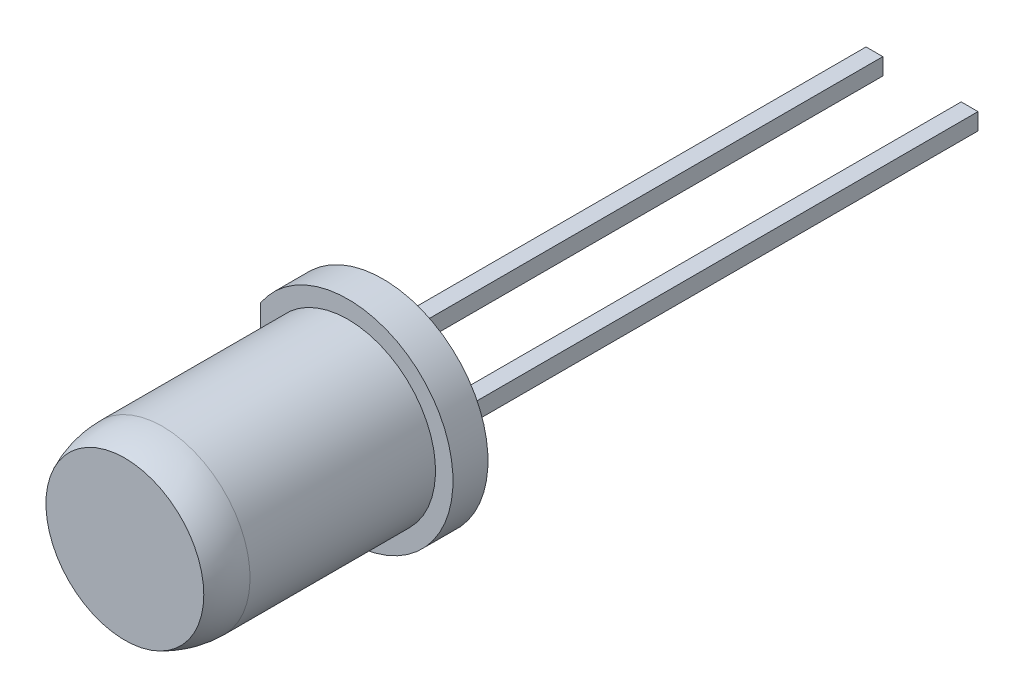
from build123d import *

# Parameters (mm, degrees)
ESBO_O1_R                  = 3
RESSALTO_EXTRUS_O1_DEPTH   = 1
CORTE_EXTRUS_O1_DEPTH      = 1
ESBO_O5_W                  = 0.48
ESBO_O5_H                  = 0.48
RESSALTO_EXTRUS_O2_DEPTH   = 25
RESSALTO_EXTRUS_O2_2_DEPTH = 25
ESBO_O6_W                  = 0.48
ESBO_O6_H                  = 0.48
RESSALTO_EXTRUS_O3_DEPTH   = 2
CORTE_EXTRUS_O2_DEPTH      = 0.24
RESSALTO_EXTRUS_O4_DEPTH   = 0.24
RESSALTO_EXTRUS_O4_2_DEPTH = 0.24
ESBO_O12_R                 = 0.2
CORTE_EXTRUS_O3_DEPTH      = 0.1
SKETCH1_W                  = 40.503516259
SKETCH1_H                  = 63.372853313
SKETCH1_W_2                = 20.905522142
SKETCH1_H_2                = 22.782231705
CUT_EXTRUDE1_DEPTH         = 4
CUT_EXTRUDE1_DEPTH_BACK    = 4


with BuildPart() as part:
    # Esboço1 → Ressalto-extrusão1 (new body)
    with BuildSketch(Plane.XY):
        Circle(ESBO_O1_R)
    extrude(amount=RESSALTO_EXTRUS_O1_DEPTH)

    # Esboço3 → Revolução1 (revolve)
    with BuildSketch(Plane(origin=(0, 0, 0), x_dir=(0, 0, -1), z_dir=(1, 0, 0))):
        with BuildLine():
            Line((-1, 0), (-8.8, 0))
            ThreePointArc((-8.8, 0), (-8.067766953, 1.767766953), (-6.3, 2.5))
            Line((-6.3, 2.5), (-1, 2.5))
            Line((-1, 2.5), (-1, 0))
        make_face()
    revolve(axis=Axis((0, 0, 1), (0, 0, 1)))

    # Esboço4 → Corte-extrusão1 (cut)
    with BuildSketch(Plane(origin=(0, 0, 0), x_dir=(-1, 0, 0), z_dir=(0, 0, -1))):
        with BuildLine():
            Line((2.5, 1.658312395), (2.5, -1.658312395))
            ThreePointArc((2.5, -1.658312395), (3, 0), (2.5, 1.658312395))
        make_face()
    extrude(amount=-CORTE_EXTRUS_O1_DEPTH, mode=Mode.SUBTRACT)

    # Esboço7 → Corte-extrusão2 (cut, symmetric)
    with BuildSketch(Plane(origin=(0, 0, 0), x_dir=(1, 0, 0), z_dir=(0, 1, 0))):
        Polygon((-1.6, 0), (-1.6, -3.5), (-1.3, -4), (1.2, -4), (0.02, -2), (-1.12, -2), (-1.12, 0), align=None)
        Polygon((1.6, 0), (1.6, -4), (1.4, -4), (0.22, -2), (1.12, -2), (1.12, 0), align=None)
    extrude(amount=CORTE_EXTRUS_O2_DEPTH, both=True, mode=Mode.SUBTRACT)


with BuildPart() as body_2:
    # Esboço5 → Ressalto-extrusão2 (new body)
    with BuildSketch(Plane(origin=(0, 0, 0), x_dir=(-1, 0, 0), z_dir=(0, 0, -1))):
        with Locations((-1.36, 0)):
            Rectangle(ESBO_O5_W, ESBO_O5_H)
    extrude(amount=RESSALTO_EXTRUS_O2_DEPTH)


with BuildPart() as body_3:
    # Esboço5 → Ressalto-extrus_o2 2 (new body)
    with BuildSketch(Plane(origin=(0, 0, 0), x_dir=(-1, 0, 0), z_dir=(0, 0, -1))):
        with Locations((1.36, 0)):
            Rectangle(ESBO_O5_W, ESBO_O5_H)
    extrude(amount=RESSALTO_EXTRUS_O2_2_DEPTH)


with BuildPart() as body_4:
    # Esboço6 → Ressalto-extrusão3 (new body)
    with BuildSketch(Plane(origin=(0, 0, -25), x_dir=(-1, 0, 0), z_dir=(0, 0, -1))):
        with Locations((-1.36, 0)):
            Rectangle(ESBO_O6_W, ESBO_O6_H)
    extrude(amount=RESSALTO_EXTRUS_O3_DEPTH)


with BuildPart() as body_5:
    # Esboço8 → Ressalto-extrusão4 (new body, symmetric)
    with BuildSketch(Plane(origin=(0, 0, 0), x_dir=(1, 0, 0), z_dir=(0, 1, 0))):
        Polygon((-1.3, -4), (1.2, -4), (0.02, -2), (-1.12, -2), (-1.12, 0), (-1.6, 0), (-1.6, -3.5), align=None)
    extrude(amount=RESSALTO_EXTRUS_O4_DEPTH, both=True)

    # Combinar2: union body 3
    add(body_3.part)

    # Esboço10 → Corte-Revolução1 (revolve, cut)
    with BuildSketch(Plane(origin=(0, 0, 0), x_dir=(1, 0, 0), z_dir=(0, 1, 0))):
        with BuildLine():
            Line((-0.05, -4), (-0.05, -3.7))
            ThreePointArc((-0.05, -3.7), (-0.341547595, -3.780754009), (-0.55, -4))
            Line((-0.55, -4), (-0.05, -4))
        make_face()
    revolve(axis=Axis((-0.05, 0, 4), (0, 0, -1)), mode=Mode.SUBTRACT)


with BuildPart() as body_6:
    # Esboço8 → Ressalto-extrus_o4 2 (new body, symmetric)
    with BuildSketch(Plane(origin=(0, 0, 0), x_dir=(1, 0, 0), z_dir=(0, 1, 0))):
        Polygon((0.22, -2), (1.4, -4), (1.6, -4), (1.6, 0), (1.12, 0), (1.12, -2), align=None)
    extrude(amount=RESSALTO_EXTRUS_O4_2_DEPTH, both=True)

    # Combinar1: union body 4, body 2
    add(body_4.part)
    add(body_2.part)


with BuildPart() as body_4_2:
    # Esboço11 → Revolução2 (revolve)
    with BuildSketch(Plane(origin=(0, 0, 0), x_dir=(1, 0, 0), z_dir=(0, 1, 0))):
        with BuildLine():
            Line((-0.55, -4), (-0.05, -4))
            Line((-0.05, -4), (-0.05, -3.7))
            ThreePointArc((-0.05, -3.7), (-0.341547595, -3.780754009), (-0.55, -4))
        make_face()
    revolve(axis=Axis((-0.05, 0, 4), (0, 0, -1)))

    # Combinar3: union body 5
    add(body_5.part)

    # Esboço12 → Corte-extrusão3 (cut)
    with BuildSketch(Plane.XY.offset(4)):
        with Locations((-0.05, 0)):
            Circle(ESBO_O12_R)
    extrude(amount=-CORTE_EXTRUS_O3_DEPTH, mode=Mode.SUBTRACT)


with BuildPart() as cut_extrude1_tool:
    # Sketch1 → Cut-Extrude1 (new body, two sides)
    with BuildSketch(Plane(origin=(0, 0, 0), x_dir=(1, 0, 0), z_dir=(0, 1, 0))) as cut_extrude1_sk:
        with Locations((0.838090288, 1.622898698)):
            Rectangle(SKETCH1_W, SKETCH1_H)
        with Locations((-0.529063495, 4.013216122)):
            Rectangle(SKETCH1_W_2, SKETCH1_H_2, mode=Mode.SUBTRACT)
    extrude(amount=CUT_EXTRUDE1_DEPTH)
    extrude(cut_extrude1_sk.sketch, amount=-CUT_EXTRUDE1_DEPTH_BACK)


with BuildPart() as part_1:
    add(part.part)

    # Cut-Extrude1: cut by cut_extrude1_tool
    add(cut_extrude1_tool.part, mode=Mode.SUBTRACT)


with BuildPart() as body_6_1:
    add(body_6.part)

    # Cut-Extrude1: cut by cut_extrude1_tool
    add(cut_extrude1_tool.part, mode=Mode.SUBTRACT)


with BuildPart() as body_4_2_1:
    add(body_4_2.part)

    # Cut-Extrude1: cut by cut_extrude1_tool
    add(cut_extrude1_tool.part, mode=Mode.SUBTRACT)


solid = Compound([part_1.part, body_6_1.part, body_4_2_1.part])
